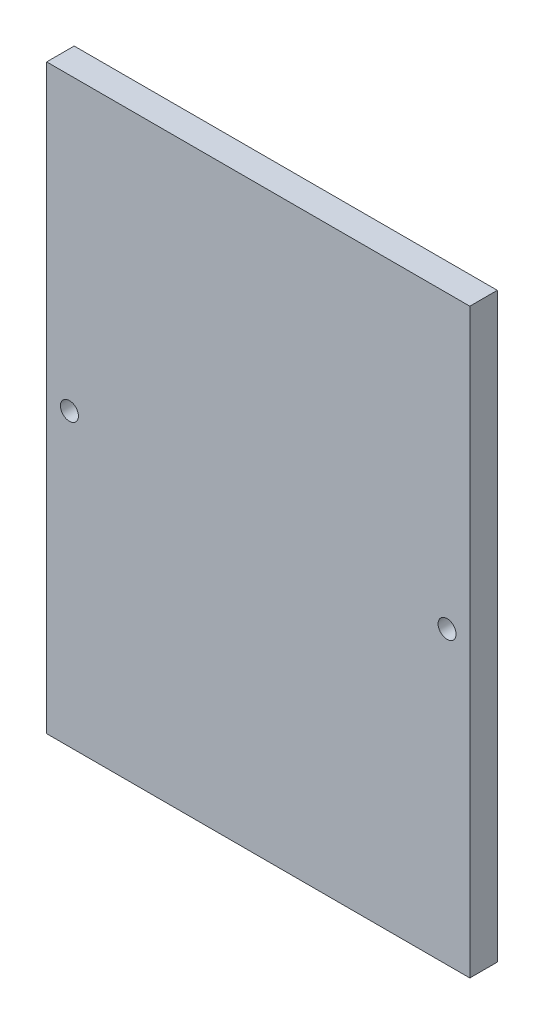
from build123d import *

# Parameters (mm, degrees)
SKETCH1_W           = 50.8
SKETCH1_H           = 69.85
BOSS_EXTRUDE2_DEPTH = 3.302
SKETCH2_R           = 1.0795
CUT_EXTRUDE1_DEPTH  = 4.302


with BuildPart() as part:
    # Sketch1 → Boss-Extrude2 (new body)
    with BuildSketch(Plane.XY):
        with Locations((-69.148342541, 30.583494475)):
            Rectangle(SKETCH1_W, SKETCH1_H)
    extrude(amount=BOSS_EXTRUDE2_DEPTH)

    # Sketch2 → Cut-Extrude1 (cut, through all)
    with BuildSketch(Plane.XY.offset(3.302)):
        with Locations((-46.478842541, 30.583494475)):
            Circle(SKETCH2_R)
        with Locations((-91.817842541, 30.583494475)):
            Circle(SKETCH2_R)
    extrude(amount=-CUT_EXTRUDE1_DEPTH, mode=Mode.SUBTRACT)


solid = part.part
